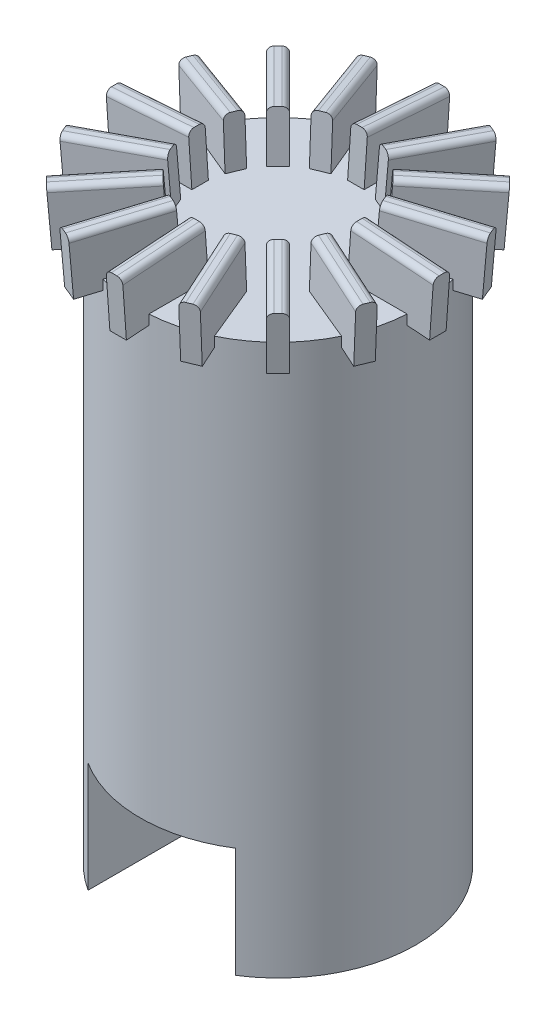
from build123d import *

# Parameters (mm, degrees)
SKETCH_1_R                       = 5
EXTRUDE_1_DEPTH                  = 20
SKETCH_3_W                       = 0.6
SKETCH_3_H                       = 3
EXTRUDE_2_DEPTH                  = 2
FILLET_1_R                       = 0.2
PATTERN_CIRCULAR_3_COUNT         = 16
FILLET_1_OF_PATTERN_CIRCULAR_3_R = 0.2
SKETCH_4_W                       = 5.353265718
SKETCH_4_H                       = 11.52836058
CUT_EXTRUDE_1_DEPTH              = 4


with BuildPart() as part:
    # 草图1 → 凸台-拉伸1 (new body)
    with BuildSketch(Plane(origin=(0, 0, 0), x_dir=(1, 0, 0), z_dir=(0, 1, 0))):
        Circle(SKETCH_1_R)
    extrude(amount=EXTRUDE_1_DEPTH)

    # 草图3 → 凸台-拉伸2 (add)
    with BuildSketch(Plane(origin=(1.423145242, 19.89821487, 0), x_dir=(0, 0, -1), z_dir=(0.071339025, 0.997452126, 0))):
        with Locations((0, -2.894865204)):
            Rectangle(SKETCH_3_W, SKETCH_3_H)
    extrude_2 = extrude(amount=EXTRUDE_2_DEPTH)

    # 圆角1
    fillet_1_edges = [part.edges().sort_by_distance(p)[0] for p in [
        (4.453312743, 21.686602261, -0.3),
        (4.453312743, 21.686602261, 0.3),
    ]]
    fillet(fillet_1_edges, radius=FILLET_1_R)

    # 阵列(圆周)3: 凸台-拉伸2 ×16 about axis
    pattern_circular_3_axis = Axis((0, 0, 0), (0, 1, 0))
    for i in range(1, PATTERN_CIRCULAR_3_COUNT):
        add(extrude_2.rotate(pattern_circular_3_axis, i * 360 / PATTERN_CIRCULAR_3_COUNT))

    # 圆角1 of 阵列(圆周)3
    fillet_1_of_pattern_circular_3_edges = [part.edges().sort_by_distance(p)[0] for p in [
        (3.999519466, 21.686602261, -1.981372866),
        (4.229129525, 21.686602261, -1.427045146),
        (2.936835605, 21.686602261, -3.361099674),
        (3.361099674, 21.686602261, -2.936835605),
        (1.427045146, 21.686602261, -4.229129525),
        (1.981372866, 21.686602261, -3.999519466),
        (-0.3, 21.686602261, -4.453312743),
        (0.3, 21.686602261, -4.453312743),
        (-1.981372866, 21.686602261, -3.999519466),
        (-1.427045146, 21.686602261, -4.229129525),
        (-3.361099674, 21.686602261, -2.936835605),
        (-2.936835605, 21.686602261, -3.361099674),
        (-4.229129525, 21.686602261, -1.427045146),
        (-3.999519466, 21.686602261, -1.981372866),
        (-4.453312743, 21.686602261, 0.3),
        (-4.453312743, 21.686602261, -0.3),
        (-3.999519466, 21.686602261, 1.981372866),
        (-4.229129525, 21.686602261, 1.427045146),
        (-2.936835605, 21.686602261, 3.361099674),
        (-3.361099674, 21.686602261, 2.936835605),
        (-1.427045146, 21.686602261, 4.229129525),
        (-1.981372866, 21.686602261, 3.999519466),
        (0.3, 21.686602261, 4.453312743),
        (-0.3, 21.686602261, 4.453312743),
        (1.981372866, 21.686602261, 3.999519466),
        (1.427045146, 21.686602261, 4.229129525),
        (3.361099674, 21.686602261, 2.936835605),
        (2.936835605, 21.686602261, 3.361099674),
        (4.229129525, 21.686602261, 1.427045146),
        (3.999519466, 21.686602261, 1.981372866),
    ]]
    fillet(fillet_1_of_pattern_circular_3_edges, radius=FILLET_1_OF_PATTERN_CIRCULAR_3_R)

    # 草图4 → 切除-拉伸1 (cut)
    with BuildSketch(Plane(origin=(0, 0, 0), x_dir=(-1, 0, 0), z_dir=(0, -1, 0))):
        Rectangle(SKETCH_4_W, SKETCH_4_H)
    extrude(amount=-CUT_EXTRUDE_1_DEPTH, mode=Mode.SUBTRACT)


solid = part.part
